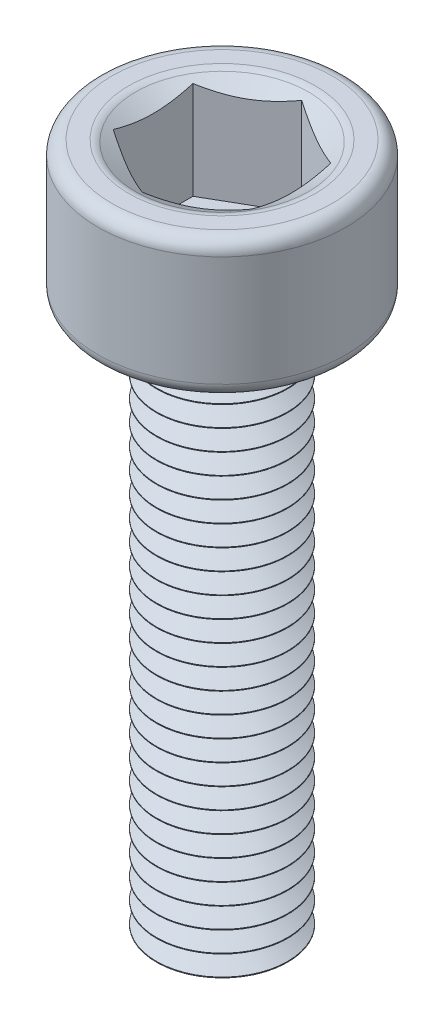
from build123d import *

# Parameters (mm, degrees)
CUT_EXTRUDE1_DEPTH = 1.5
SKETCH3_R          = 1.3
CUT_EXTRUDE2_DEPTH = 1
CUT_EXTRUDE2_DRAFT = -60
FILLET1_R          = 0.2
LPATTERN1_COUNT    = 26
LPATTERN1_PITCH    = 0.3


with BuildPart() as part:
    # Sketch1 → Revolve1 (revolve)
    with BuildSketch(Plane.XY):
        with BuildLine():
            Line((0, 2), (0, -8))
            Line((0, -8), (0.95, -8))
            Line((0.95, -8), (0.95, 0))
            Line((0.95, 0), (1.6, 0))
            ThreePointArc((1.6, 0), (1.741421356, 0.058578644), (1.8, 0.2))
            Line((1.8, 0.2), (1.8, 1.8))
            ThreePointArc((1.8, 1.8), (1.741421356, 1.941421356), (1.6, 2))
            Line((1.6, 2), (0, 2))
        make_face()
    revolve(axis=Axis((0, 2, 0), (0, -1, 0)))

    # Sketch2 → Cut-Extrude1 (cut)
    with BuildSketch(Plane(origin=(0, 2, 0), x_dir=(1, 0, 0), z_dir=(0, 1, 0))):
        Polygon((1, 0.577350269), (0, 1.154700538), (-1, 0.577350269), (-1, -0.577350269), (0, -1.154700538), (1, -0.577350269), align=None)
    extrude(amount=-CUT_EXTRUDE1_DEPTH, mode=Mode.SUBTRACT)


with BuildPart() as cut_extrude2_tool:
    # Sketch3 → Cut-Extrude2 (with draft: the straight prism first)
    with BuildSketch(Plane(origin=(0, 2, 0), x_dir=(1, 0, 0), z_dir=(0, 1, 0))):
        Circle(SKETCH3_R)
    extrude(amount=-CUT_EXTRUDE2_DEPTH)
    # Cut-Extrude2: the draft: its side faces are tilted about the plane it starts from
    cut_extrude2_sides = [cut_extrude2_tool.faces().sort_by_distance(p)[0] for p in [
        (-1.3, 1.5, 0),
    ]]
    draft(cut_extrude2_sides, Plane(origin=(0, 2, 0), x_dir=(1, 0, 0), z_dir=(0, 1, 0)), CUT_EXTRUDE2_DRAFT)


with BuildPart() as part_1:
    add(part.part)

    # Cut-Extrude2: cut by cut_extrude2_tool
    add(cut_extrude2_tool.part, mode=Mode.SUBTRACT)

    # Fillet1
    fillet1_edges = [part_1.edges().sort_by_distance(p)[0] for p in [
        (-1.3, 2, 0),
    ]]
    fillet(fillet1_edges, radius=FILLET1_R)

    # Sketch4 → Cut-Revolve1 (revolve, cut)
    with BuildSketch(Plane.XY):
        Polygon((1.259807621, -7.85), (1.259807621, -8.15), (0.959807621, -8.15), (0.7, -8), (0.959807621, -7.85), align=None)
    cut_revolve1 = revolve(axis=Axis((0, 0, 0), (0, -1, 0)), mode=Mode.SUBTRACT)

    # LPattern1: Cut-Revolve1 ×26
    with Locations(*[(0, i * LPATTERN1_PITCH, 0) for i in range(1, LPATTERN1_COUNT)]):
        add(cut_revolve1, mode=Mode.SUBTRACT)


solid = part_1.part
